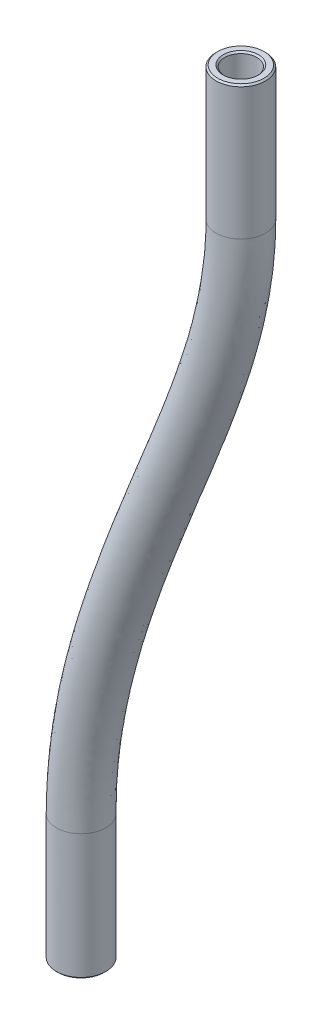
from build123d import *

# Parameters (mm, degrees)
SKETCH1_R     = 2
SKETCH1_R_2   = 1.3
CHAMFER1_SIZE = 0.127


with BuildPart() as part:
    # Sweep1: sweep along a curve in space
    with BuildLine() as sweep1_path:
        Line((-150.085279081, -93.282256564, -25.525), (-150.085279081, -103.482256564, -25.525))
        add(Edge.make_bspline(
            [(-138.631112316, -46.6, -27.001603743), (-138.631112316, -53.418290009, -27.001603743), (-144.358195699, -68.791470848, -26.263301872), (-150.085279081, -83.943708487, -25.525), (-150.085279081, -93.282256564, -25.525)],
            knots=[0, 0, 0, 0, 0.425348976, 1, 1, 1, 1], degree=3))
        Line((-138.631112316, -35.8, -27.001603743), (-138.631112316, -46.6, -27.001603743))
    # Sketch1 → Sweep1 (sweep)
    with BuildSketch(Plane(origin=(0, -95.382256564, 0), x_dir=(1, 0, 0), z_dir=(0, 1, 0))):
        with Locations((-150.085279081, 25.525)):
            Circle(SKETCH1_R)
        with Locations((-150.085279081, 25.525)):
            Circle(SKETCH1_R_2, mode=Mode.SUBTRACT)
    sweep(path=sweep1_path.line)

    # Chamfer1
    chamfer1_edges = [part.edges().sort_by_distance(p)[0] for p in [
        (-139.931112316, -35.8, -27.001603743),
        (-140.631112316, -35.8, -27.001603743),
        (-151.385279081, -103.482256564, -25.525),
        (-152.085279081, -103.482256564, -25.525),
    ]]
    chamfer(chamfer1_edges, length=CHAMFER1_SIZE)


solid = part.part
